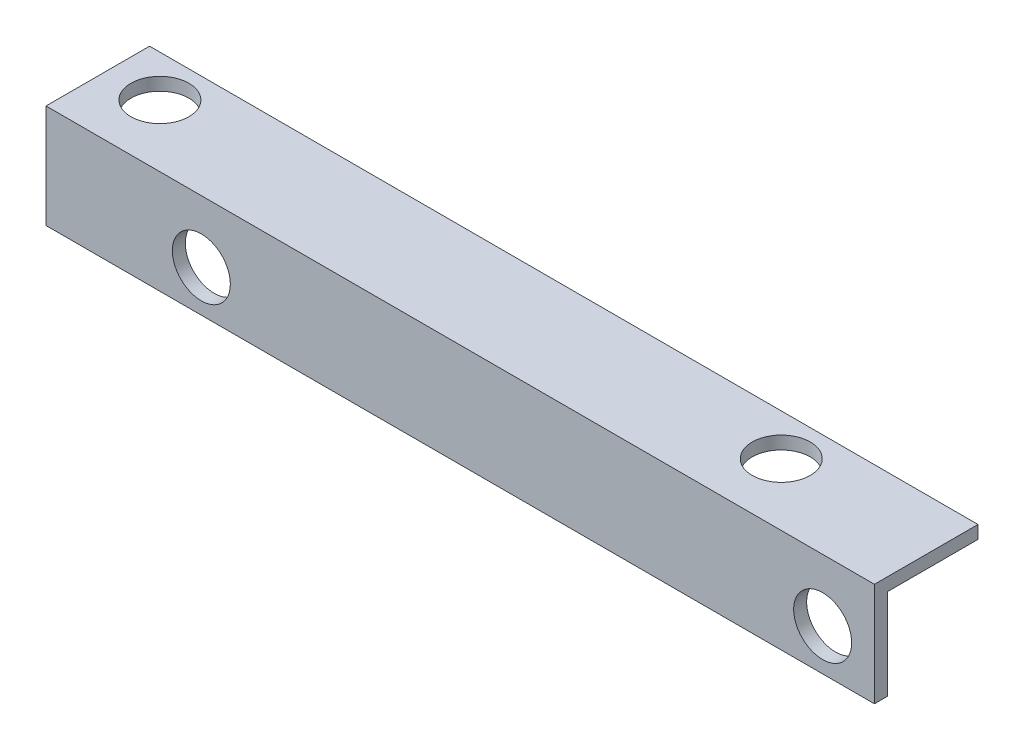
from build123d import *

# Parameters (mm, degrees)
BOSS_EXTRUDE1_DEPTH      = 44.45
BOSS_EXTRUDE1_DEPTH_BACK = 57.15
SKETCH3_R                = 3.556
CUT_EXTRUDE1_DEPTH       = 13.7
SKETCH5_R                = 3.556
CUT_EXTRUDE2_DEPTH       = 13.7


with BuildPart() as part:
    # Sketch1 → Boss-Extrude1 (new body, two sides)
    with BuildSketch(Plane(origin=(0, 0, 0), x_dir=(0, 0, -1), z_dir=(1, 0, 0))) as boss_extrude1_sk:
        Polygon((0, 0), (0, 12.7), (12.7, 12.7), (12.7, 11.1125), (1.5875, 11.1125), (1.5875, 0), align=None)
    extrude(amount=BOSS_EXTRUDE1_DEPTH)
    extrude(boss_extrude1_sk.sketch, amount=-BOSS_EXTRUDE1_DEPTH_BACK)

    # Sketch3 → Cut-Extrude1 (cut, through all)
    with BuildSketch(Plane.XY):
        with Locations((-38.1, 5.08)):
            Circle(SKETCH3_R)
        with Locations((38.1, 5.08)):
            Circle(SKETCH3_R)
    extrude(amount=-CUT_EXTRUDE1_DEPTH, mode=Mode.SUBTRACT)

    # Sketch5 → Cut-Extrude2 (cut, through all)
    with BuildSketch(Plane(origin=(0, 12.7, 0), x_dir=(1, 0, 0), z_dir=(0, 1, 0))):
        with Locations((-50.8, 7.62)):
            Circle(SKETCH5_R)
        with Locations((25.4, 7.62)):
            Circle(SKETCH5_R)
    extrude(amount=-CUT_EXTRUDE2_DEPTH, mode=Mode.SUBTRACT)


solid = part.part
